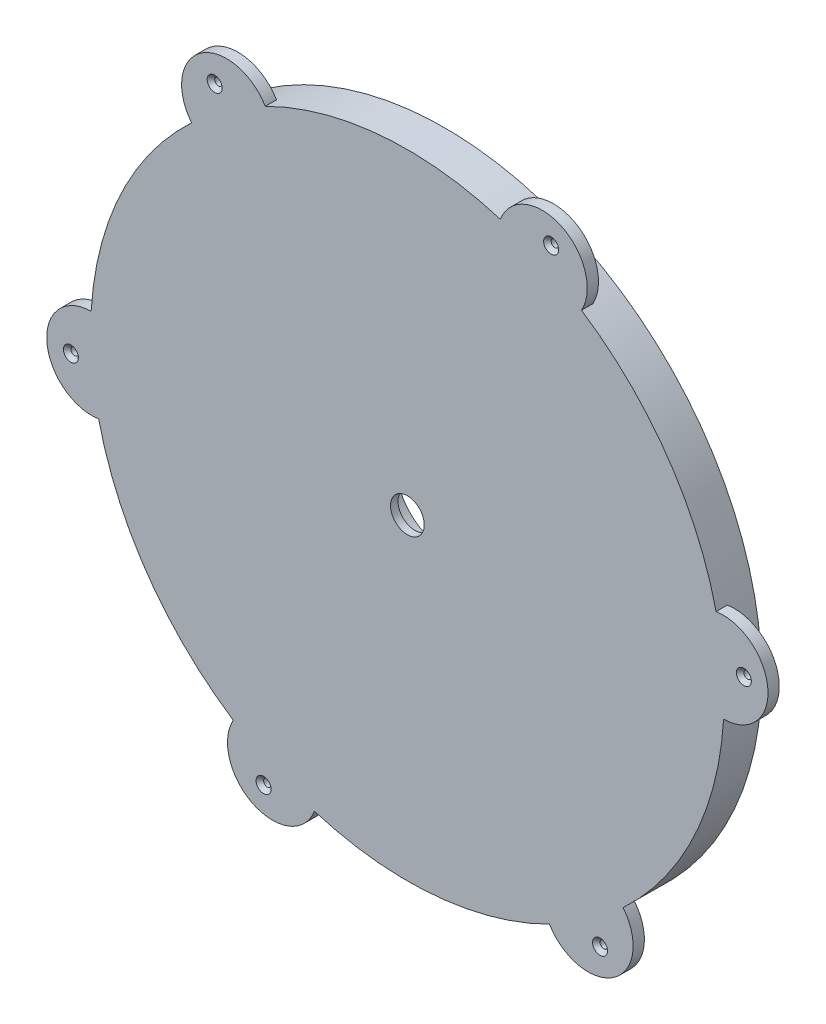
from build123d import *

# Parameters (mm, degrees)
SKETCH1_R                                       = 84.5
SKETCH1_R_2                                     = 4.5
BOSS_EXTRUDE1_DEPTH                             = 10
SKETCH2_R                                       = 13
CUT_EXTRUDE1_DEPTH                              = 8
SKETCH3_R                                       = 12
BOSS_EXTRUDE2_DEPTH                             = 3
CIRPATTERN1_COUNT                               = 6
CSK_FOR_M2_FLAT_HEAD_MACHINE_SCREW1_D           = 2
CSK_FOR_M2_FLAT_HEAD_MACHINE_SCREW1_CSINK_D     = 4
CSK_FOR_M2_FLAT_HEAD_MACHINE_SCREW1_CSINK_ANGLE = 90
CIRPATTERN2_COUNT                               = 6


with BuildPart() as part:
    # Sketch1 → Boss-Extrude1 (new body)
    with BuildSketch(Plane.XY):
        Circle(SKETCH1_R)
        Circle(SKETCH1_R_2, mode=Mode.SUBTRACT)
    extrude(amount=BOSS_EXTRUDE1_DEPTH)

    # Sketch2 → Cut-Extrude1 (cut)
    with BuildSketch(Plane.XY):
        Circle(SKETCH2_R)
    extrude(amount=CUT_EXTRUDE1_DEPTH, mode=Mode.SUBTRACT)

    # Sketch3 → Boss-Extrude2 (add)
    with BuildSketch(Plane.XY.offset(10)):
        with Locations((84.204250337, 7.063584439)):
            Circle(SKETCH3_R)
    boss_extrude2 = extrude(amount=-BOSS_EXTRUDE2_DEPTH)

    # CirPattern1: Boss-Extrude2 ×6 about axis
    cirpattern1_axis = Axis((0, 0, 0), (0, 0, 1))
    for i in range(1, CIRPATTERN1_COUNT):
        add(boss_extrude2.rotate(cirpattern1_axis, i * 360 / CIRPATTERN1_COUNT))

    # CSK for M2 Flat Head Machine Screw1 (through all)
    with Locations(Plane(origin=(89.758705981, 7.529527266, 10), x_dir=(1, 0, 0), z_dir=(0, 0, 1))):
        with Locations((0, 0)):
            csk_for_m2_flat_head_machine_screw1 = CounterSinkHole(CSK_FOR_M2_FLAT_HEAD_MACHINE_SCREW1_D / 2, CSK_FOR_M2_FLAT_HEAD_MACHINE_SCREW1_CSINK_D / 2, counter_sink_angle=CSK_FOR_M2_FLAT_HEAD_MACHINE_SCREW1_CSINK_ANGLE)

    # CirPattern2: CSK for M2 Flat Head Machine Screw1 ×6 about axis
    cirpattern2_axis = Axis((0, 0, 0), (0, 0, 1))
    for i in range(1, CIRPATTERN2_COUNT):
        add(csk_for_m2_flat_head_machine_screw1.rotate(cirpattern2_axis, i * 360 / CIRPATTERN2_COUNT), mode=Mode.SUBTRACT)


solid = part.part
